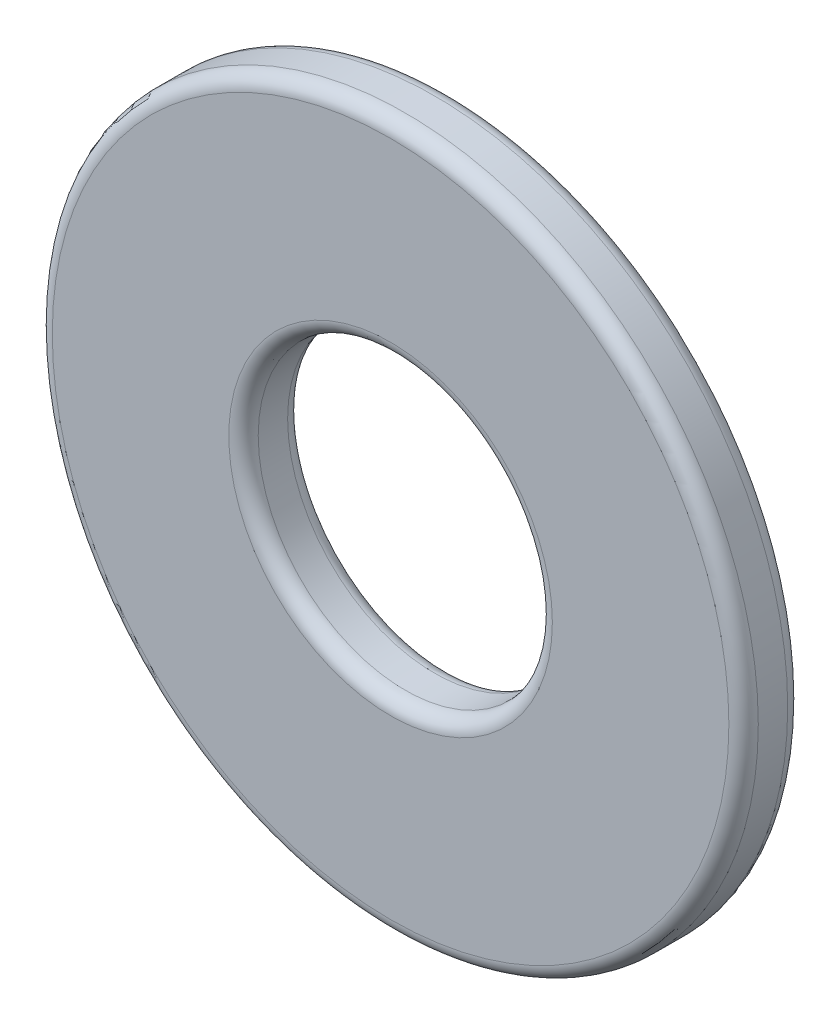
from build123d import *

# Parameters (mm, degrees)
SKETCH1_R           = 3
SKETCH1_R_2         = 1.25
BOSS_EXTRUDE1_DEPTH = 0.5
FILLET1_R           = 0.125


with BuildPart() as part:
    # Sketch1 → Boss-Extrude1 (new body)
    with BuildSketch(Plane.XY):
        Circle(SKETCH1_R)
        Circle(SKETCH1_R_2, mode=Mode.SUBTRACT)
    extrude(amount=BOSS_EXTRUDE1_DEPTH)

    # Fillet1
    fillet1_edges = [part.edges().sort_by_distance(p)[0] for p in [
        (-3, 0, 0),
        (-3, 0, 0.5),
        (-1.25, 0, 0),
        (-1.25, 0, 0.5),
    ]]
    fillet(fillet1_edges, radius=FILLET1_R)


solid = part.part
